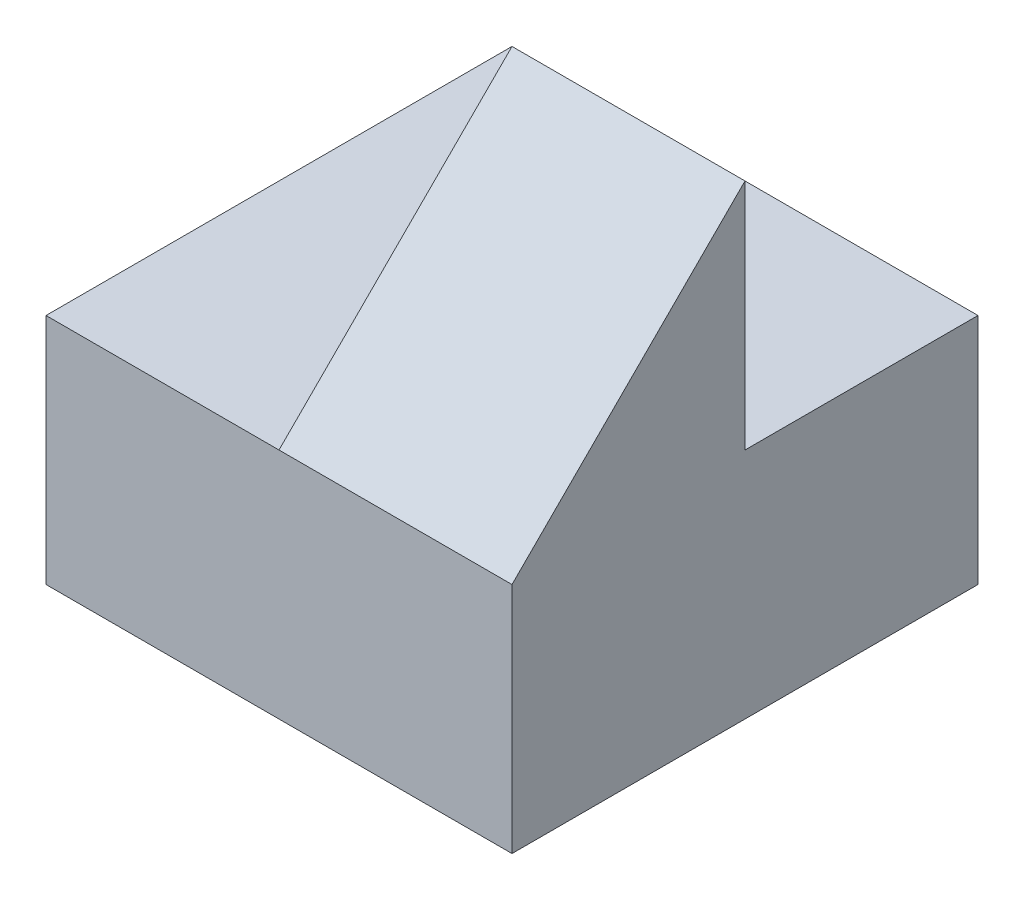
from build123d import *

# Parameters (mm, degrees)
SKETCH1_W           = 4
SKETCH1_H           = 4
BOSS_EXTRUDE1_DEPTH = 4
CUT_EXTRUDE1_DEPTH  = 2
CUT_EXTRUDE2_DEPTH  = 10


with BuildPart() as part:
    # Sketch1 → Boss-Extrude1 (new body)
    with BuildSketch(Plane(origin=(0, 0, 0), x_dir=(1, 0, 0), z_dir=(0, 1, 0))):
        with Locations((2, 2)):
            Rectangle(SKETCH1_W, SKETCH1_H)
    extrude(amount=BOSS_EXTRUDE1_DEPTH)

    # Sketch2 → Cut-Extrude1 (cut)
    with BuildSketch(Plane(origin=(0, 4, 0), x_dir=(1, 0, 0), z_dir=(0, 1, 0))):
        Polygon((2, 0), (2, 2), (4, 2), (4, 4), (0, 4), (0, 0), align=None)
    extrude(amount=-CUT_EXTRUDE1_DEPTH, mode=Mode.SUBTRACT)

    # Sketch3 → Cut-Extrude2 (cut)
    with BuildSketch(Plane.ZY):
        Polygon((0, 2), (0, 4), (-2, 4), align=None)
    extrude(amount=-CUT_EXTRUDE2_DEPTH, mode=Mode.SUBTRACT)


solid = part.part
